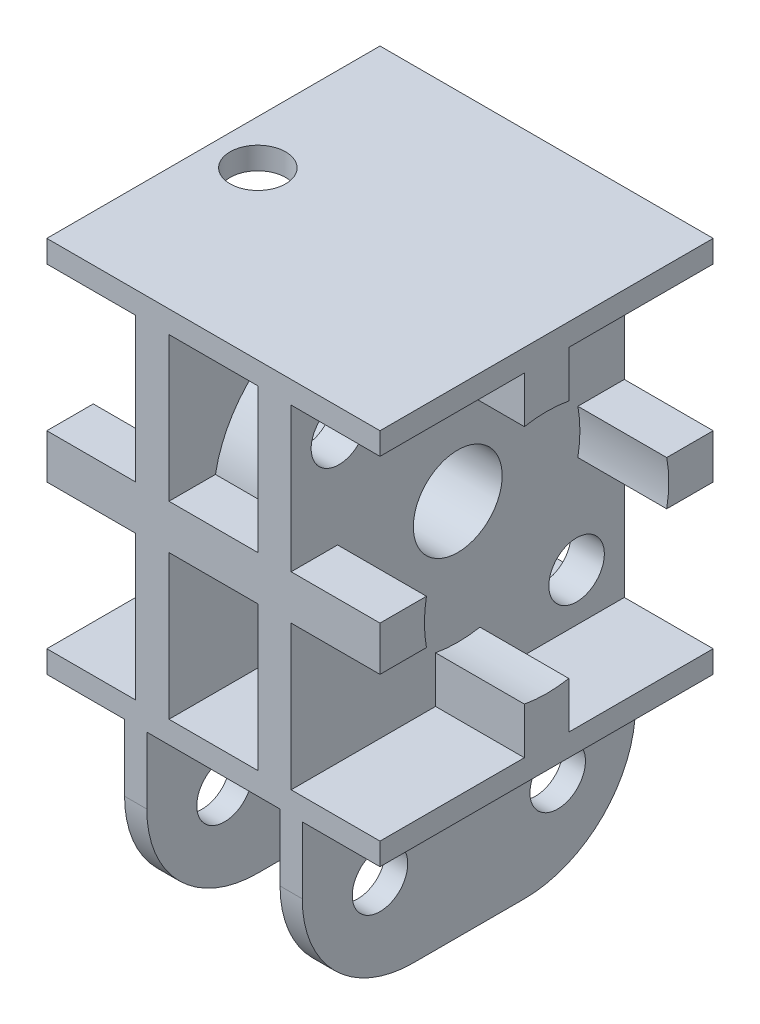
from build123d import *

# Parameters (mm, degrees)
CROQUIS1_W              = 8
CROQUIS1_H              = 13
SALIENTE_EXTRUIR1_DEPTH = 15
CROQUIS3_R              = 11
CORTAR_EXTRUIR1_DEPTH   = 15
CROQUIS4_R              = 2.5
CORTAR_EXTRUIR2_DEPTH   = 30
REDONDEO1_R             = 10
CROQUIS5_R              = 2.5
CORTAR_EXTRUIR3_DEPTH   = 2
BOSS_EXTRUDE1_REACH     = 44.403
SKETCH2_R               = 2.5
CUT_EXTRUDE1_DEPTH      = 3
BOSS_EXTRUDE2_START     = -14
SKETCH3_R               = 11
SKETCH3_R_2             = 4
BOSS_EXTRUDE2_DEPTH     = 14
SKETCH4_R               = 2.5
BOSS_EXTRUDE4_DEPTH     = 2


with BuildPart() as part:
    # Croquis1 → Saliente-Extruir1 (new, symmetric)
    with BuildSketch(Plane.XY):
        Polygon((-15, -2), (-7, -2), (-7, -15), (-15, -15), (-15, -17), (-8, -17), (-8, -33), (-6, -33), (-6, -17), (6, -17), (6, -33), (8, -33), (8, -17), (15, -17), (15, -15), (7, -15), (7, -2), (15, -2), (15, 2), (7, 2), (7, 15), (15, 15), (15, 17), (-15, 17), (-15, 15), (-7, 15), (-7, 2), (-15, 2), align=None)
        with Locations((0, 8.5)):
            Rectangle(CROQUIS1_W, CROQUIS1_H, mode=Mode.SUBTRACT)
        with Locations((0, -8.5)):
            Rectangle(CROQUIS1_W, CROQUIS1_H, mode=Mode.SUBTRACT)
    extrude(amount=SALIENTE_EXTRUIR1_DEPTH, both=True)

    # Croquis3 → Cortar-Extruir1 (cut, symmetric)
    with BuildSketch(Plane(origin=(0, 0, 0), x_dir=(0, 0, -1), z_dir=(1, 0, 0))):
        with Locations(Location((0, 0, 0), (0, 0, 10.475681696))):
            Circle(CROQUIS3_R)
    extrude(amount=CORTAR_EXTRUIR1_DEPTH, both=True, mode=Mode.SUBTRACT)

    # Croquis4 → Cortar-Extruir2 (cut)
    with BuildSketch(Plane(origin=(8, 0, 0), x_dir=(0, 0, -1), z_dir=(1, 0, 0))):
        with Locations(Location((-8, -25, 0), (0, 0, 90))):
            Circle(CROQUIS4_R)
        with Locations(Location((8, -25, 0), (0, 0, 90))):
            Circle(CROQUIS4_R)
    extrude(amount=-CORTAR_EXTRUIR2_DEPTH, mode=Mode.SUBTRACT)

    # Redondeo1
    redondeo1_edges = [part.edges().sort_by_distance(p)[0] for p in [
        (7, -33, -15),
        (-7, -33, -15),
        (-7, -33, 15),
        (7, -33, 15),
    ]]
    fillet(redondeo1_edges, radius=REDONDEO1_R)

    # Croquis5 → Cortar-Extruir3 (cut)
    with BuildSketch(Plane(origin=(0, 17, 0), x_dir=(1, 0, 0), z_dir=(0, 1, 0))):
        with Locations(Location((-11, 0, 0), (0, 0, 270))):
            Circle(CROQUIS5_R)
        with Locations(Location((11, 0, 0), (0, 0, 270))):
            Circle(CROQUIS5_R)
    extrude(amount=-CORTAR_EXTRUIR3_DEPTH, mode=Mode.SUBTRACT)

    # Boss-Extrude1: up to this face of the body (flat: up to its plane)
    boss_extrude1_end = Plane(part.part.faces().sort_by_distance((15, 0, 12.969177885))[0])
    # Sketch1 → Boss-Extrude1 (add, up to the picked face)
    with BuildSketch(Plane(origin=(7, 0, 0), x_dir=(0, 0, -1), z_dir=(1, 0, 0)), mode=Mode.PRIVATE) as boss_extrude1_sk1:
        with BuildLine():
            Line((-2, 15), (2, 15))
            Line((2, 15), (2, 10.816653826))
            ThreePointArc((2, 10.816653826), (0, 11), (-2, 10.816653826))
            Line((-2, 10.816653826), (-2, 15))
        make_face()
    boss_extrude1_tool1 = split(extrude(boss_extrude1_sk1.sketch, amount=BOSS_EXTRUDE1_REACH, mode=Mode.PRIVATE), bisect_by=boss_extrude1_end, keep=Keep.BOTH, mode=Mode.PRIVATE)
    boss_extrude1 = boss_extrude1_tool1.solids().sort_by(Axis((7, 12.969178, 0), (1, 0, 0)))[0]
    add(boss_extrude1)

    # Mirror1: Boss-Extrude1 across plane
    add(boss_extrude1.mirror(Plane.ZX))

    # Sketch2 → Cut-Extrude1 (cut)
    with BuildSketch(Plane(origin=(7, 0, 0), x_dir=(0, 0, -1), z_dir=(1, 0, 0))):
        with Locations(Location((-10.7, 10.7, 0), (0, 0, 90))):
            Circle(SKETCH2_R)
        with Locations(Location((10.7, -10.7, 0), (0, 0, 90))):
            Circle(SKETCH2_R)
    extrude(amount=-CUT_EXTRUDE1_DEPTH, mode=Mode.SUBTRACT)

    # Sketch3 → Boss-Extrude2 (add)
    with BuildSketch(Plane.ZY.offset(7).offset(BOSS_EXTRUDE2_START)):
        Circle(SKETCH3_R)
        with Locations(Location((0, 0, 0), (0, 0, 270))):
            Circle(SKETCH3_R_2, mode=Mode.SUBTRACT)
    boss_extrude2 = extrude(amount=BOSS_EXTRUDE2_DEPTH)

    # Mirror2: Boss-Extrude2 across plane
    add(boss_extrude2.mirror(Plane(origin=(0, 0, 0), x_dir=(0, 0, 1), z_dir=(1, 0, 0))))

    # Sketch4 → Boss-Extrude4 (add)
    with BuildSketch(Plane(origin=(0, 17, 0), x_dir=(1, 0, 0), z_dir=(0, 1, 0))):
        with Locations((11, 0)):
            Circle(SKETCH4_R)
    extrude(amount=-BOSS_EXTRUDE4_DEPTH)


solid = part.part
